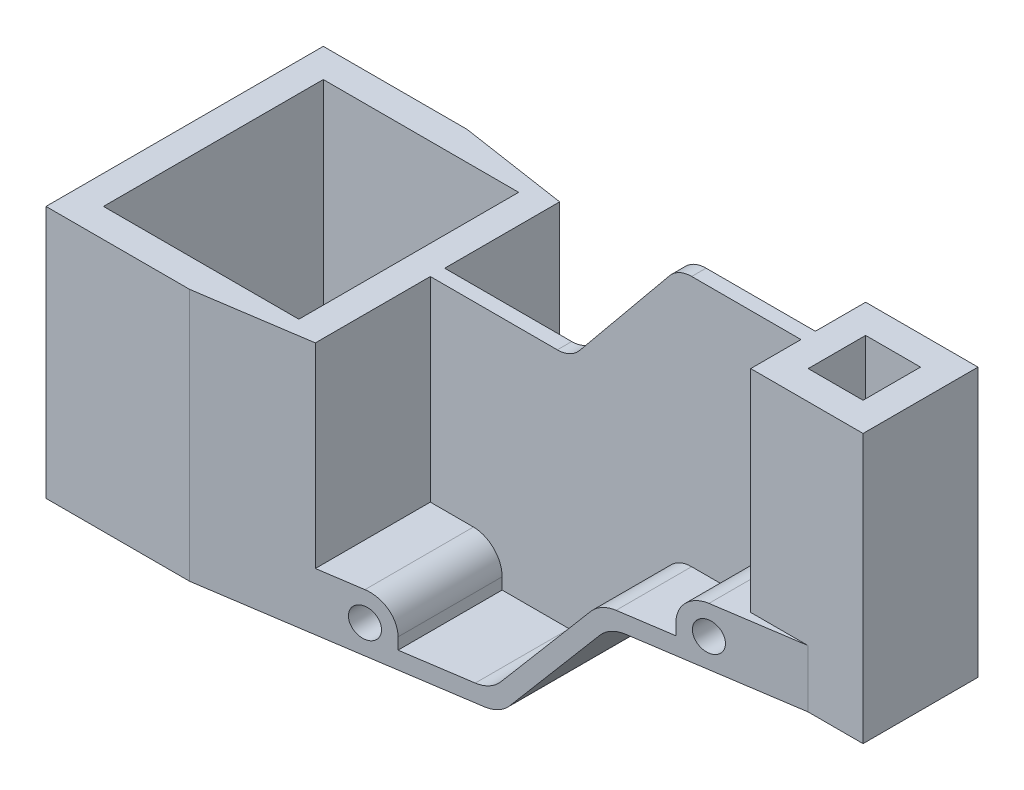
from build123d import *

# Parameters (mm, degrees)
SKETCH1_W                = 256.103174946
SKETCH1_H                = 133.5
BOSS_EXTRUDE1_DEPTH      = 48.25
SKETCH2_W                = 88
SKETCH2_H                = 45.5
CUT_EXTRUDE1_DEPTH       = 96.5
SKETCH4_W                = 39.103174946
SKETCH4_H                = 40
CUT_EXTRUDE2_DEPTH       = 96.5
SKETCH5_W                = 68
SKETCH5_H                = 76.5
CUT_EXTRUDE3_DEPTH       = 88
CUT_EXTRUDE4_DEPTH       = 133.5
CUT_EXTRUDE5_DEPTH       = 88
CUT_EXTRUDE6_DEPTH       = 88
SKETCH9_W                = 19.103174946
SKETCH9_H                = 20
CUT_EXTRUDE7_DEPTH       = 93.5
CUT_EXTRUDE8_DEPTH       = 73.5
CUT_EXTRUDE9_DEPTH       = 45.5
SKETCH17_W               = 46.042780748
SKETCH17_H               = 40
CUT_EXTRUDE12_DEPTH      = 40
CUT_EXTRUDE13_DEPTH      = 28
SKETCH23_W               = 40
SKETCH23_H               = 40
CUT_EXTRUDE20_DEPTH      = 8
SKETCH24_W               = 40
SKETCH24_H               = 40
CUT_EXTRUDE21_DEPTH      = 8
CUT_EXTRUDE22_DEPTH      = 14
CUT_EXTRUDE23_DEPTH      = 14
CUT_EXTRUDE24_DEPTH      = 30
CUT_EXTRUDE24_DEPTH_BACK = 30
SKETCH29_R               = 5
FILLET1_R                = 10
CUT_EXTRUDE25_DEPTH      = 26
CUT_EXTRUDE26_DEPTH      = 26
CUT_EXTRUDE28_DEPTH      = 40
CUT_EXTRUDE29_DEPTH      = 40
CUT_EXTRUDE30_DEPTH      = 40
CUT_EXTRUDE30_DEPTH_BACK = 40
FILLET2_R                = 10
FILLET3_R                = 10
FILLET4_R                = 10
CUT_EXTRUDE31_DEPTH      = 40
CUT_EXTRUDE31_DEPTH_BACK = 40
CUT_EXTRUDE32_DEPTH      = 2.5
CUT_EXTRUDE32_DEPTH_BACK = 2.5
CUT_EXTRUDE33_DEPTH      = 43
CUT_EXTRUDE33_DEPTH_BACK = 43
SKETCH53_R               = 5
BOSS_EXTRUDE4_DEPTH      = 2.5
BOSS_EXTRUDE4_DEPTH_BACK = 2.5
FILLET7_R                = 10


with BuildPart() as part:
    # Sketch1 → Boss-Extrude1 (new, symmetric)
    with BuildSketch(Plane.XY):
        with Locations((72.471204682, 26.669157508)):
            Rectangle(SKETCH1_W, SKETCH1_H)
    extrude(amount=BOSS_EXTRUDE1_DEPTH, both=True)

    # Sketch2 → Cut-Extrude1 (cut)
    with BuildSketch(Plane.XY.offset(48.25)):
        with Locations((-11.580382791, 70.669157508)):
            Rectangle(SKETCH2_W, SKETCH2_H)
    extrude(amount=-CUT_EXTRUDE1_DEPTH, mode=Mode.SUBTRACT)

    # Sketch4 → Cut-Extrude2 (cut)
    with BuildSketch(Plane.XY.offset(48.25)):
        with Locations((180.971204682, -20.080842492)):
            Rectangle(SKETCH4_W, SKETCH4_H)
    extrude(amount=-CUT_EXTRUDE2_DEPTH, mode=Mode.SUBTRACT)

    # Sketch5 → Cut-Extrude3 (cut)
    with BuildSketch(Plane(origin=(0, 47.919157508, 0), x_dir=(1, 0, 0), z_dir=(0, 1, 0))):
        with Locations((-11.580382791, 0)):
            Rectangle(SKETCH5_W, SKETCH5_H)
    extrude(amount=-CUT_EXTRUDE3_DEPTH, mode=Mode.SUBTRACT)

    # Sketch6 → Cut-Extrude4 (cut)
    with BuildSketch(Plane(origin=(0, 93.419157508, 0), x_dir=(1, 0, 0), z_dir=(0, 1, 0))):
        Polygon((200.522792155, 48.25), (200.522792155, 20), (181.419617209, 20), (32.419617209, 42.509358289), (32.419617209, 48.25), align=None)
        Polygon((200.522792155, -48.25), (200.522792155, -20), (181.419617209, -20), (32.419617209, -42.509358289), (32.419617209, -48.25), align=None)
    extrude(amount=-CUT_EXTRUDE4_DEPTH, mode=Mode.SUBTRACT)

    # Sketch7 → Cut-Extrude5 (cut)
    with BuildSketch(Plane(origin=(0, 47.919157508, 0), x_dir=(1, 0, 0), z_dir=(0, 1, 0))):
        Polygon((-5.580382791, 48.25), (32.419617209, 42.509358289), (32.419617209, 48.25), align=None)
    extrude(amount=-CUT_EXTRUDE5_DEPTH, mode=Mode.SUBTRACT)

    # Sketch8 → Cut-Extrude6 (cut)
    with BuildSketch(Plane(origin=(0, 47.919157508, 0), x_dir=(1, 0, 0), z_dir=(0, 1, 0))):
        Polygon((-5.580382791, -48.25), (32.419617209, -42.509358289), (32.419617209, -48.25), align=None)
    extrude(amount=-CUT_EXTRUDE6_DEPTH, mode=Mode.SUBTRACT)

    # Sketch9 → Cut-Extrude7 (cut)
    with BuildSketch(Plane(origin=(0, 93.419157508, 0), x_dir=(1, 0, 0), z_dir=(0, 1, 0))):
        with Locations((180.971204682, 0)):
            Rectangle(SKETCH9_W, SKETCH9_H)
    extrude(amount=-CUT_EXTRUDE7_DEPTH, mode=Mode.SUBTRACT)

    # Sketch10 → Cut-Extrude8 (cut)
    with BuildSketch(Plane(origin=(0, 93.419157508, 0), x_dir=(1, 0, 0), z_dir=(0, 1, 0))):
        Polygon((161.419617209, 20), (181.419617209, 20), (161.419617209, 23.021390374), align=None)
        Polygon((181.419617209, -20), (161.419617209, -20), (161.419617209, -23.021390374), align=None)
    extrude(amount=-CUT_EXTRUDE8_DEPTH, mode=Mode.SUBTRACT)

    # Sketch14 → Cut-Extrude9 (cut)
    with BuildSketch(Plane(origin=(0, 93.419157508, 0), x_dir=(1, 0, 0), z_dir=(0, 1, 0))):
        Polygon((161.419617209, 20), (161.419617209, 2.5), (32.419617209, 2.5), (32.419617209, 42.509358289), (161.419617209, 23.021390374), align=None)
        Polygon((161.419617209, -20), (161.419617209, -2.5), (32.419617209, -2.5), (32.419617209, -42.509358289), (161.419617209, -23.021390374), align=None)
    extrude(amount=-CUT_EXTRUDE9_DEPTH, mode=Mode.SUBTRACT)

    # Sketch17 → Cut-Extrude12 (cut)
    with BuildSketch(Plane(origin=(161.419617209, 0, 0), x_dir=(0, 0, -1), z_dir=(1, 0, 0))):
        with Locations((0, -20.080842492)):
            Rectangle(SKETCH17_W, SKETCH17_H)
    extrude(amount=-CUT_EXTRUDE12_DEPTH, mode=Mode.SUBTRACT)

    # Sketch19 → Cut-Extrude13 (cut)
    with BuildSketch(Plane(origin=(0, 47.919157508, 0), x_dir=(1, 0, 0), z_dir=(0, 1, 0))):
        Polygon((32.419617209, -2.5), (32.419617209, -42.509358289), (161.419617209, -23.021390374), (161.419617209, -20), (161.419617209, -2.5), align=None)
        Polygon((32.419617209, 2.5), (32.419617209, 42.509358289), (161.419617209, 23.021390374), (161.419617209, 2.5), align=None)
    extrude(amount=-CUT_EXTRUDE13_DEPTH, mode=Mode.SUBTRACT)

    # Sketch23 → Cut-Extrude20 (cut)
    with BuildSketch(Plane(origin=(0, 0, 23.021390374), x_dir=(-1, 0, 0), z_dir=(0, 0, -1))):
        with Locations((-141.419617209, -20.080842492)):
            Rectangle(SKETCH23_W, SKETCH23_H)
    extrude(amount=-CUT_EXTRUDE20_DEPTH, mode=Mode.SUBTRACT)

    # Sketch24 → Cut-Extrude21 (cut)
    with BuildSketch(Plane.XY.offset(-23.021390374)):
        with Locations((141.419617209, -20.080842492)):
            Rectangle(SKETCH24_W, SKETCH24_H)
    extrude(amount=-CUT_EXTRUDE21_DEPTH, mode=Mode.SUBTRACT)

    # Sketch26 → Cut-Extrude22 (cut)
    with BuildSketch(Plane(origin=(0, 19.919157508, 0), x_dir=(1, 0, 0), z_dir=(0, 1, 0))):
        Polygon((141.419617209, -2.5), (141.419617209, -26.042780749), (32.419617209, -42.509358289), (32.419617209, -2.5), align=None)
    extrude(amount=-CUT_EXTRUDE22_DEPTH, mode=Mode.SUBTRACT)

    # Sketch27 → Cut-Extrude23 (cut)
    with BuildSketch(Plane(origin=(0, 19.919157508, 0), x_dir=(1, 0, 0), z_dir=(0, 1, 0))):
        Polygon((141.419617209, 2.5), (32.419617209, 2.5), (32.419617209, 42.509358289), (141.419617209, 26.042780749), align=None)
    extrude(amount=-CUT_EXTRUDE23_DEPTH, mode=Mode.SUBTRACT)

    # Sketch29 → Cut-Extrude24 (cut, two sides: drawn at the far end of the back side and taken through both)
    with BuildSketch(Plane.XY.offset(-CUT_EXTRUDE24_DEPTH_BACK)):
        with Locations((151.419617209, 9.919157508)):
            Circle(SKETCH29_R)
    extrude(amount=CUT_EXTRUDE24_DEPTH + CUT_EXTRUDE24_DEPTH_BACK, mode=Mode.SUBTRACT)

    # Fillet1
    fillet1_edges = [part.edges().sort_by_distance(p)[0] for p in [
        (141.419617209, 19.919157508, 14.271390374),
    ]]
    fillet(fillet1_edges, radius=FILLET1_R)

    # Sketch31 → Cut-Extrude25 (cut)
    with BuildSketch(Plane(origin=(0, 5.919157508, 0), x_dir=(1, 0, 0), z_dir=(0, 1, 0))):
        Polygon((32.419617209, -2.5), (57.419617209, -2.5), (57.419617209, -38.732620321), (32.419617209, -42.509358289), align=None)
    extrude(amount=-CUT_EXTRUDE25_DEPTH, mode=Mode.SUBTRACT)

    # Sketch32 → Cut-Extrude26 (cut)
    with BuildSketch(Plane(origin=(0, 5.919157508, 0), x_dir=(1, 0, 0), z_dir=(0, 1, 0))):
        Polygon((32.419617209, 2.5), (57.419617209, 2.5), (57.419617209, 38.732620321), (32.419617209, 42.509358289), align=None)
    extrude(amount=-CUT_EXTRUDE26_DEPTH, mode=Mode.SUBTRACT)

    # Sketch40 → Cut-Extrude28 (cut)
    with BuildSketch(Plane(origin=(0, 5.919157508, 0), x_dir=(1, 0, 0), z_dir=(0, 1, 0))):
        Polygon((57.419617209, 38.732620321), (81.352447073, 35.117099232), (81.352447073, 2.5), (57.419617209, 2.5), align=None)
    extrude(amount=-CUT_EXTRUDE28_DEPTH, mode=Mode.SUBTRACT)

    # Sketch41 → Cut-Extrude29 (cut)
    with BuildSketch(Plane(origin=(0, 5.919157508, 0), x_dir=(1, 0, 0), z_dir=(0, 1, 0))):
        Polygon((57.419617209, -2.5), (57.419617209, -38.732620321), (81.352447073, -35.117099232), (81.352447073, -2.5), align=None)
    extrude(amount=-CUT_EXTRUDE29_DEPTH, mode=Mode.SUBTRACT)

    # Sketch43 → Cut-Extrude30 (cut, two sides: drawn at the far end of the back side and taken through both)
    with BuildSketch(Plane.XY.offset(-CUT_EXTRUDE30_DEPTH_BACK)):
        Polygon((88.23219723, -40.080842492), (121.419617209, -0.080842492), (121.419617209, -40.080842492), align=None)
    extrude(amount=CUT_EXTRUDE30_DEPTH + CUT_EXTRUDE30_DEPTH_BACK, mode=Mode.SUBTRACT)

    # Fillet2
    fillet2_edges = [part.edges().sort_by_distance(p)[0] for p in [
        (88.23219723, -40.080842492, 0),
        (121.419617209, -0.080842492, 0),
    ]]
    fillet(fillet2_edges, radius=FILLET2_R)

    # Fillet3
    fillet3_edges = [part.edges().sort_by_distance(p)[0] for p in [
        (57.419617209, -20.080842492, 20.61631016),
    ]]
    fillet(fillet3_edges, radius=FILLET3_R)

    # Fillet4
    fillet4_edges = [part.edges().sort_by_distance(p)[0] for p in [
        (57.419617209, -20.080842492, -20.61631016),
    ]]
    fillet(fillet4_edges, radius=FILLET4_R)

    # Sketch44 → Cut-Extrude31 (cut, two sides: drawn at the far end of the back side and taken through both)
    with BuildSketch(Plane.XY.offset(-CUT_EXTRUDE31_DEPTH_BACK)):
        Polygon((81.352447073, 5.919157508), (118.653161204, 5.919157508), (85.465741224, -34.080842492), (81.352447073, -34.080842492), align=None)
    extrude(amount=CUT_EXTRUDE31_DEPTH + CUT_EXTRUDE31_DEPTH_BACK, mode=Mode.SUBTRACT)

    # Sketch49 → Cut-Extrude32 (cut, two sides: drawn at the far end of the back side and taken through both)
    with BuildSketch(Plane.XY.offset(-CUT_EXTRUDE32_DEPTH_BACK)):
        Polygon((118.653161204, 5.919157508), (118.653161204, 93.419157508), (32.419617209, 93.419157508), (32.419617209, 47.919157508), (81.352447073, 47.919157508), (81.352447073, 5.919157508), align=None)
    extrude(amount=CUT_EXTRUDE32_DEPTH + CUT_EXTRUDE32_DEPTH_BACK, mode=Mode.SUBTRACT)

    # Sketch53 → Cut-Extrude33 (cut, two sides: drawn at the far end of the back side and taken through both)
    with BuildSketch(Plane.XY.offset(-CUT_EXTRUDE33_DEPTH_BACK)):
        with Locations((47.419617209, -30.080842492)):
            Circle(SKETCH53_R)
    extrude(amount=CUT_EXTRUDE33_DEPTH + CUT_EXTRUDE33_DEPTH_BACK, mode=Mode.SUBTRACT)

    # Sketch55 → Boss-Extrude4 (add, two sides: drawn at the far end of the back side and taken through both)
    with BuildSketch(Plane.XY.offset(-BOSS_EXTRUDE4_DEPTH_BACK)):
        Polygon((81.352447073, 47.919157508), (118.653161204, 93.419157508), (118.653161204, 5.919157508), (85.465741224, -34.080842492), (80.854981216, -34.080842492), align=None)
    extrude(amount=BOSS_EXTRUDE4_DEPTH + BOSS_EXTRUDE4_DEPTH_BACK)

    # Fillet7
    fillet7_edges = [part.edges().sort_by_distance(p)[0] for p in [
        (85.465741224, -34.080842492, -18.497852932),
        (118.653161204, 5.919157508, -15.99104915),
        (141.419617209, 19.919157508, -14.271390374),
        (81.352447073, 47.919157508, 0),
        (118.653161204, 93.419157508, 0),
        (85.465741224, -34.080842492, 18.497852932),
        (118.653161204, 5.919157508, 15.99104915),
    ]]
    fillet(fillet7_edges, radius=FILLET7_R)


solid = part.part
